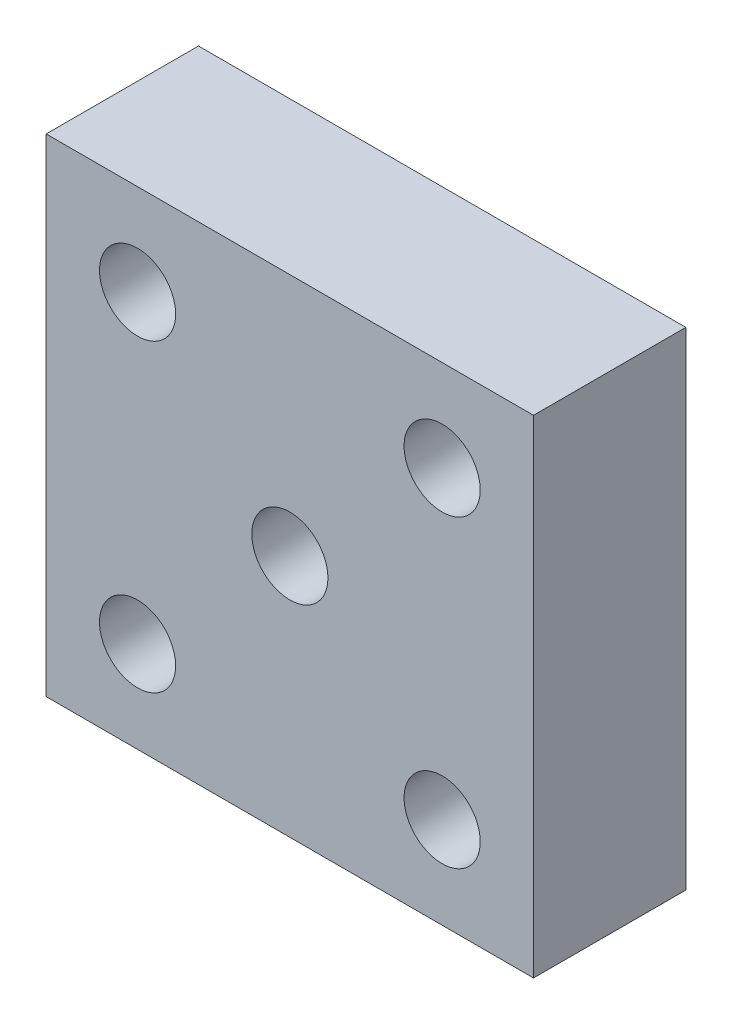
from build123d import *

# Parameters (mm, degrees)
SKETCH1_W           = 16
SKETCH1_H           = 16
SKETCH1_R           = 1.25
BOSS_EXTRUDE1_DEPTH = 5


with BuildPart() as part:
    # Sketch1 → Boss-Extrude1 (new body)
    with BuildSketch(Plane.XY):
        Rectangle(SKETCH1_W, SKETCH1_H)
        with Locations((-5, 5)):
            Circle(SKETCH1_R, mode=Mode.SUBTRACT)
        with Locations((5, 5)):
            Circle(SKETCH1_R, mode=Mode.SUBTRACT)
        with Locations((5, -5)):
            Circle(SKETCH1_R, mode=Mode.SUBTRACT)
        with Locations((-5, -5)):
            Circle(SKETCH1_R, mode=Mode.SUBTRACT)
        Circle(SKETCH1_R, mode=Mode.SUBTRACT)
    extrude(amount=BOSS_EXTRUDE1_DEPTH)


solid = part.part
